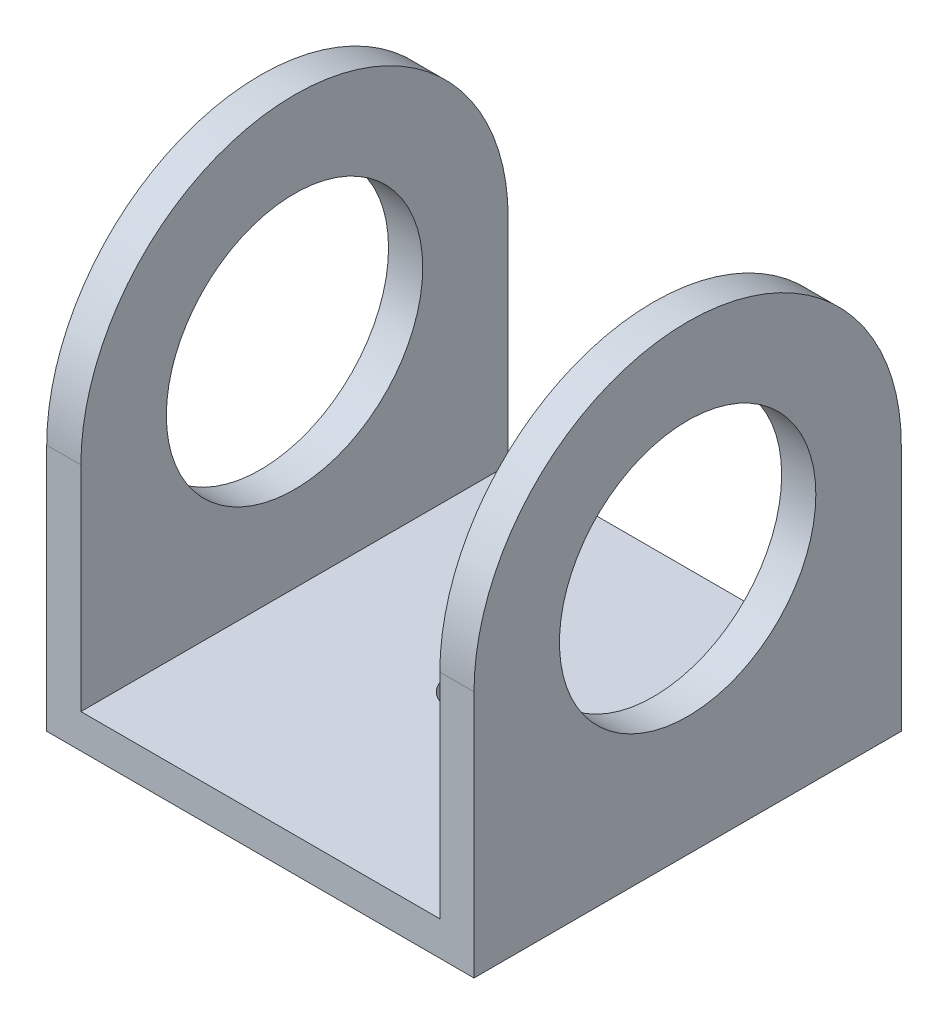
from build123d import *

# Parameters (mm, degrees)
SKETCH1_W           = 50.8
SKETCH1_H           = 50.8
SKETCH1_R           = 3.175
BOSS_EXTRUDE1_DEPTH = 4.064
SKETCH2_W           = 4.064
SKETCH2_H           = 50.8
BOSS_EXTRUDE2_DEPTH = 50.8
SKETCH3_R           = 15.24
CUT_EXTRUDE1_DEPTH  = 51.8
CUT_EXTRUDE2_DEPTH  = 51.8


with BuildPart() as part:
    # Sketch1 → Boss-Extrude1 (new body)
    with BuildSketch(Plane(origin=(0, 0, 0), x_dir=(1, 0, 0), z_dir=(0, 1, 0))):
        Rectangle(SKETCH1_W, SKETCH1_H)
        Circle(SKETCH1_R, mode=Mode.SUBTRACT)
    extrude(amount=BOSS_EXTRUDE1_DEPTH)

    # Sketch2 → Boss-Extrude2 (add)
    with BuildSketch(Plane(origin=(0, 4.064, 0), x_dir=(1, 0, 0), z_dir=(0, 1, 0))):
        with Locations((-23.368, 0)):
            Rectangle(SKETCH2_W, SKETCH2_H)
        with Locations((23.368, 0)):
            Rectangle(SKETCH2_W, SKETCH2_H)
    extrude(amount=BOSS_EXTRUDE2_DEPTH)

    # Sketch3 → Cut-Extrude1 (cut, through all)
    with BuildSketch(Plane(origin=(25.4, 0, 0), x_dir=(0, 0, -1), z_dir=(1, 0, 0))):
        with Locations((0, 29.464)):
            Circle(SKETCH3_R)
    extrude(amount=-CUT_EXTRUDE1_DEPTH, mode=Mode.SUBTRACT)

    # Sketch4 → Cut-Extrude2 (cut, through all)
    with BuildSketch(Plane.ZY.offset(25.4)):
        with BuildLine():
            ThreePointArc((-25.4, 29.464), (-17.960512262, 47.424512222), (-5.6e-08, 54.864))
            Line((-5.6e-08, 54.864), (-25.4, 54.864))
            Line((-25.4, 54.864), (-25.4, 29.464))
        make_face()
        with BuildLine():
            ThreePointArc((-5.6e-08, 54.864), (17.960512222, 47.424512262), (25.4, 29.464))
            Line((25.4, 29.464), (25.4, 54.864))
            Line((25.4, 54.864), (-5.6e-08, 54.864))
        make_face()
    extrude(amount=-CUT_EXTRUDE2_DEPTH, mode=Mode.SUBTRACT)


solid = part.part
